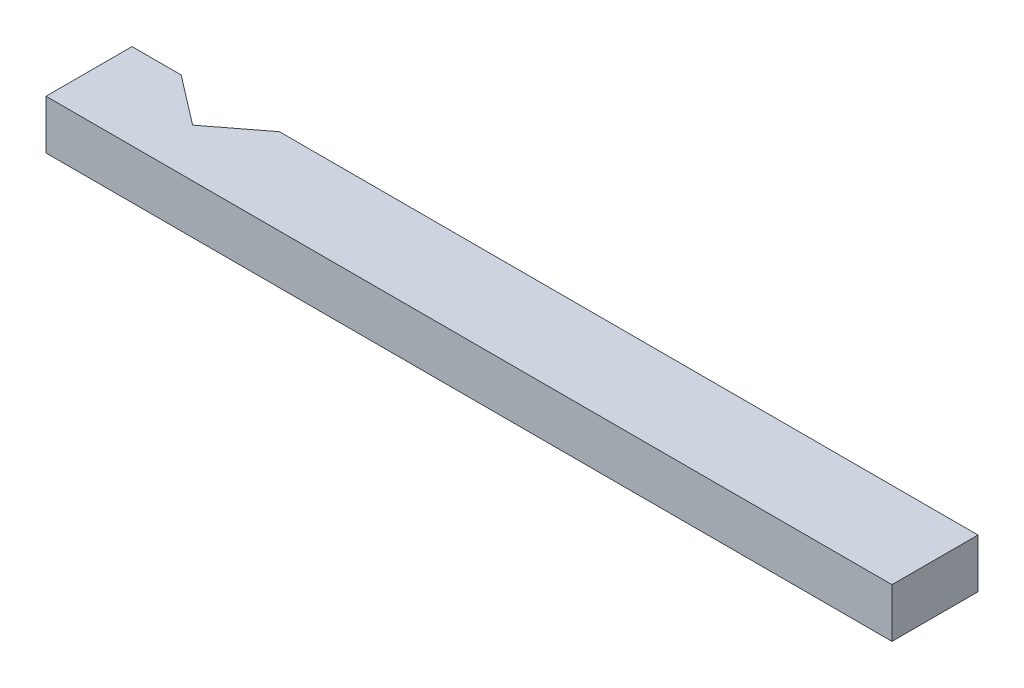
from build123d import *

# Parameters (mm, degrees)
SKETCH1_W           = 874.395
SKETCH1_H           = 88.9
BOSS_EXTRUDE1_DEPTH = 25.4
CUT_EXTRUDE1_DEPTH  = 51.8


with BuildPart() as part:
    # Sketch1 → Boss-Extrude1 (new body, symmetric)
    with BuildSketch(Plane(origin=(0, 0, 0), x_dir=(1, 0, 0), z_dir=(0, 1, 0))):
        Rectangle(SKETCH1_W, SKETCH1_H)
    extrude(amount=BOSS_EXTRUDE1_DEPTH, both=True)

    # Sketch2 → Cut-Extrude1 (cut, through all)
    with BuildSketch(Plane(origin=(0, 25.4, 0), x_dir=(1, 0, 0), z_dir=(0, 1, 0))):
        Polygon((-386.3975, 44.45), (-335.5975, 5.469789011), (-284.7975, 44.45), align=None)
    extrude(amount=-CUT_EXTRUDE1_DEPTH, mode=Mode.SUBTRACT)


solid = part.part
